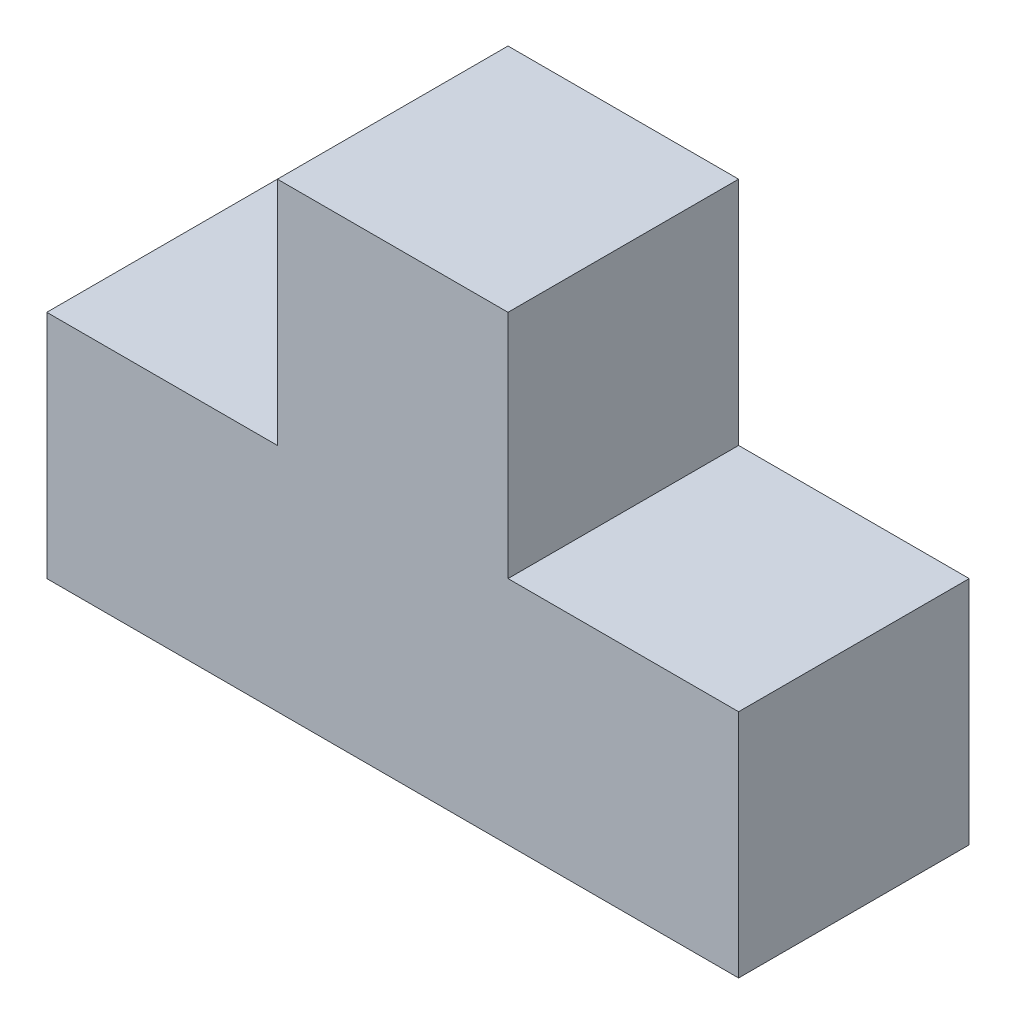
from build123d import *

# Parameters (mm, degrees)
BOSS_EXTRUDE1_DEPTH = 30


with BuildPart() as part:
    # Sketch1 → Boss-Extrude1 (new body)
    with BuildSketch(Plane.XY):
        Polygon((-45, 0), (45, 0), (45, 30), (15, 30), (15, 60), (-15, 60), (-15, 30), (-45, 30), align=None)
    extrude(amount=-BOSS_EXTRUDE1_DEPTH)


solid = part.part
